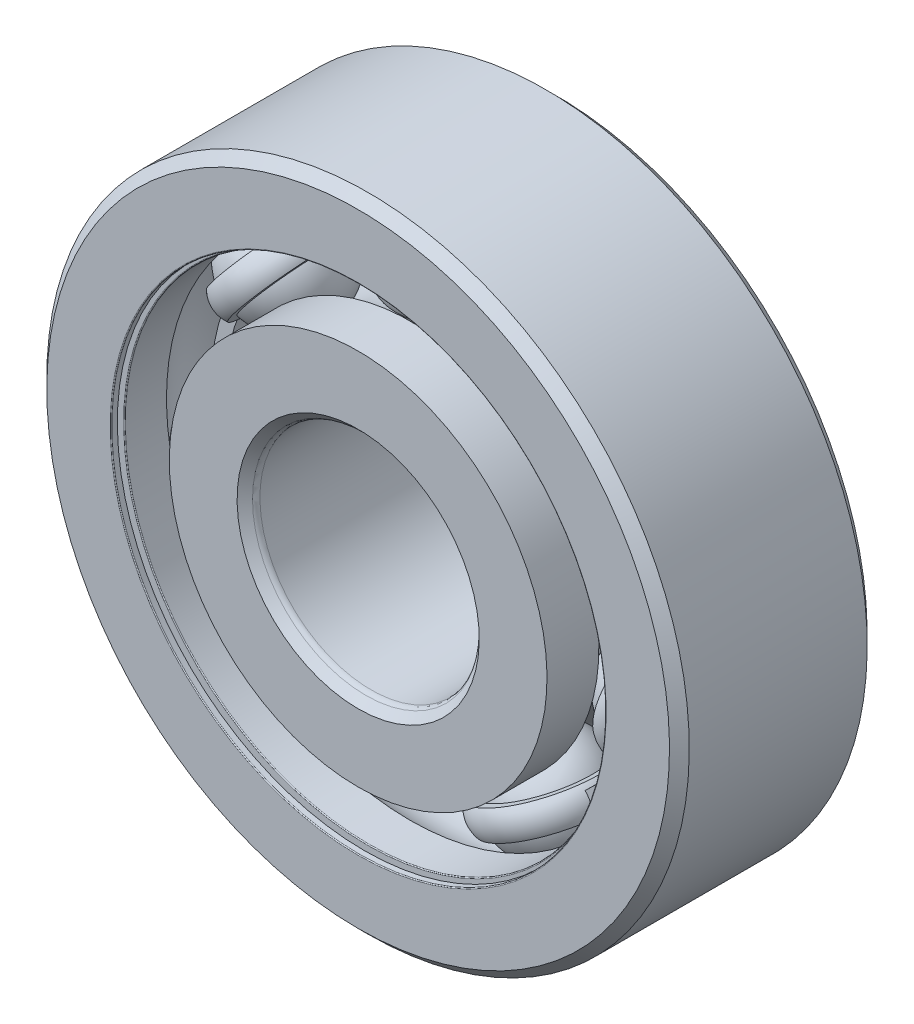
from build123d import *

# Parameters (mm, degrees)
BOSS_EXTRUDE1_DEPTH = 0.666666667
CIRPATTERN1_COUNT   = 7
CIRPATTERN2_COUNT   = 7
FILLET1_R           = 0.036
FILLET2_R           = 0.3


with BuildPart() as part:
    # Sketch3 → Revolve1 (revolve)
    with BuildSketch(Plane(origin=(0, 0, 0), x_dir=(0, 0, -1), z_dir=(1, 0, 0))):
        with BuildLine():
            Line((3.6, 13), (4, 12.6))
            Line((4, 12.6), (4, 9.857692308))
            Line((4, 9.857692308), (1.9, 9.857692308))
            ThreePointArc((1.9, 9.857692308), (0, 10.94931404), (-1.9, 9.857692308))
            Line((-1.9, 9.857692308), (-4, 9.857692308))
            Line((-4, 9.857692308), (-4, 12.6))
            Line((-4, 12.6), (-3.6, 13))
            Line((-3.6, 13), (3.6, 13))
        make_face()
    revolve(axis=Axis((0, 0, 4), (0, 0, -1)))

    # Sketch8 → Cut-Revolve1 (revolve, cut)
    with BuildSketch(Plane(origin=(0, 0, 0), x_dir=(0, 0, -1), z_dir=(1, 0, 0))):
        Polygon((-3.744, 9.857692308), (-3.6, 9.857692308), (-3.6, 10.905128205), (-3.744, 10.905128205), (-3.744, 10.001692308), (-4, 10.001692308), (-4, 9.857692308), align=None)
        Polygon((3.6, 9.857692308), (3.744, 9.857692308), (4, 9.857692308), (4, 10.001692308), (3.744, 10.001692308), (3.744, 10.905128205), (3.6, 10.905128205), align=None)
    revolve(axis=Axis((0, 0, 4), (0, 0, -1)), mode=Mode.SUBTRACT)

    # Fillet1
    fillet1_edges = [part.edges().sort_by_distance(p)[0] for p in [
        (0, -9.857692308, -3.6),
        (0, -10.001692308, -4),
        (0, -9.857692308, 3.6),
        (0, -10.001692308, 4),
    ]]
    fillet(fillet1_edges, radius=FILLET1_R)


with BuildPart() as body_2:
    # Sketch4 → Revolve2 (revolve)
    with BuildSketch(Plane(origin=(0, 0, 0), x_dir=(0, 0, -1), z_dir=(1, 0, 0))):
        with BuildLine():
            Line((-3.6, 4.5), (-4, 4.9))
            Line((-4, 4.9), (-4, 7.642307692))
            Line((-4, 7.642307692), (-1.9, 7.642307692))
            ThreePointArc((-1.9, 7.642307692), (0, 6.55068596), (1.9, 7.642307692))
            Line((1.9, 7.642307692), (4, 7.642307692))
            Line((4, 7.642307692), (4, 4.9))
            Line((4, 4.9), (3.6, 4.5))
            Line((3.6, 4.5), (-3.6, 4.5))
        make_face()
    revolve(axis=Axis((0, 0, 4), (0, 0, -1)))

    # Fillet2
    fillet2_edges = [body_2.edges().sort_by_distance(p)[0] for p in [
        (0, -4.5, -3.6),
        (0, -4.5, 3.6),
    ]]
    fillet(fillet2_edges, radius=FILLET2_R)


with BuildPart() as body_3:
    # Sketch5 → Revolve3 (revolve)
    with BuildSketch(Plane(origin=(0, 0, 0), x_dir=(0, 0, -1), z_dir=(1, 0, 0))):
        with BuildLine():
            Line((-2.19931404, 8.75), (2.19931404, 8.75))
            ThreePointArc((2.19931404, 8.75), (0, 10.94931404), (-2.19931404, 8.75))
        make_face()
    revolve(axis=Axis((0, 8.75, 2.19931404), (0, 0, -1)))


with BuildPart() as body_4:
    # Sketch6 → Revolve4 (revolve)
    with BuildSketch(Plane(origin=(0, 0, 0), x_dir=(0, 0, -1), z_dir=(1, 0, 0))):
        with BuildLine():
            Line((-2.128435267, 9.303846154), (-2.440362723, 9.303846154))
            ThreePointArc((-2.440362723, 9.303846154), (-2.59632645, 8.75), (-2.440362723, 8.196153846))
            Line((-2.440362723, 8.196153846), (-2.128435267, 8.196153846))
            ThreePointArc((-2.128435267, 8.196153846), (-2.19931404, 8.75), (-2.128435267, 9.303846154))
        make_face()
    revolve4 = revolve(axis=Axis((0, 13, 0), (0, -1, 0)))

    # Sketch7 → Boss-Extrude1 (add, symmetric)
    with BuildSketch(Plane.XY):
        with BuildLine():
            Line((6.841025472, 5.455535766), (7.274039831, 5.800853195))
            ThreePointArc((7.274039831, 5.800853195), (4.036787557, 8.382475736), (0, 9.303846154))
            Line((0, 9.303846154), (0, 8.75))
            ThreePointArc((0, 8.75), (3.796482717, 7.883477594), (6.841025472, 5.455535766))
        make_face()
    boss_extrude1 = extrude(amount=BOSS_EXTRUDE1_DEPTH, both=True)

    # CirPattern2: Revolve4, Boss-Extrude1 ×7 about axis
    cirpattern2_axis = Axis((0, 0, 4), (0, 0, -1))
    add([revolve4.rotate(cirpattern2_axis, i * 360 / CIRPATTERN2_COUNT) for i in range(1, CIRPATTERN2_COUNT)])
    add([boss_extrude1.rotate(cirpattern2_axis, i * 360 / CIRPATTERN2_COUNT) for i in range(1, CIRPATTERN2_COUNT)])


with BuildPart() as cirpattern1_1:
    # CirPattern1: pattern copy
    add(body_3.part.rotate(Axis((0, 0, 4), (0, 0, -1)), 1 * 360 / CIRPATTERN1_COUNT))


with BuildPart() as cirpattern1_2:
    # CirPattern1: pattern copy
    add(body_3.part.rotate(Axis((0, 0, 4), (0, 0, -1)), 2 * 360 / CIRPATTERN1_COUNT))


with BuildPart() as cirpattern1_3:
    # CirPattern1: pattern copy
    add(body_3.part.rotate(Axis((0, 0, 4), (0, 0, -1)), 3 * 360 / CIRPATTERN1_COUNT))


with BuildPart() as cirpattern1_4:
    # CirPattern1: pattern copy
    add(body_3.part.rotate(Axis((0, 0, 4), (0, 0, -1)), 4 * 360 / CIRPATTERN1_COUNT))


with BuildPart() as cirpattern1_5:
    # CirPattern1: pattern copy
    add(body_3.part.rotate(Axis((0, 0, 4), (0, 0, -1)), 5 * 360 / CIRPATTERN1_COUNT))


with BuildPart() as cirpattern1_6:
    # CirPattern1: pattern copy
    add(body_3.part.rotate(Axis((0, 0, 4), (0, 0, -1)), 6 * 360 / CIRPATTERN1_COUNT))


solid = Compound([part.part, body_2.part, body_3.part, body_4.part, cirpattern1_1.part, cirpattern1_2.part, cirpattern1_3.part, cirpattern1_4.part, cirpattern1_5.part, cirpattern1_6.part])
